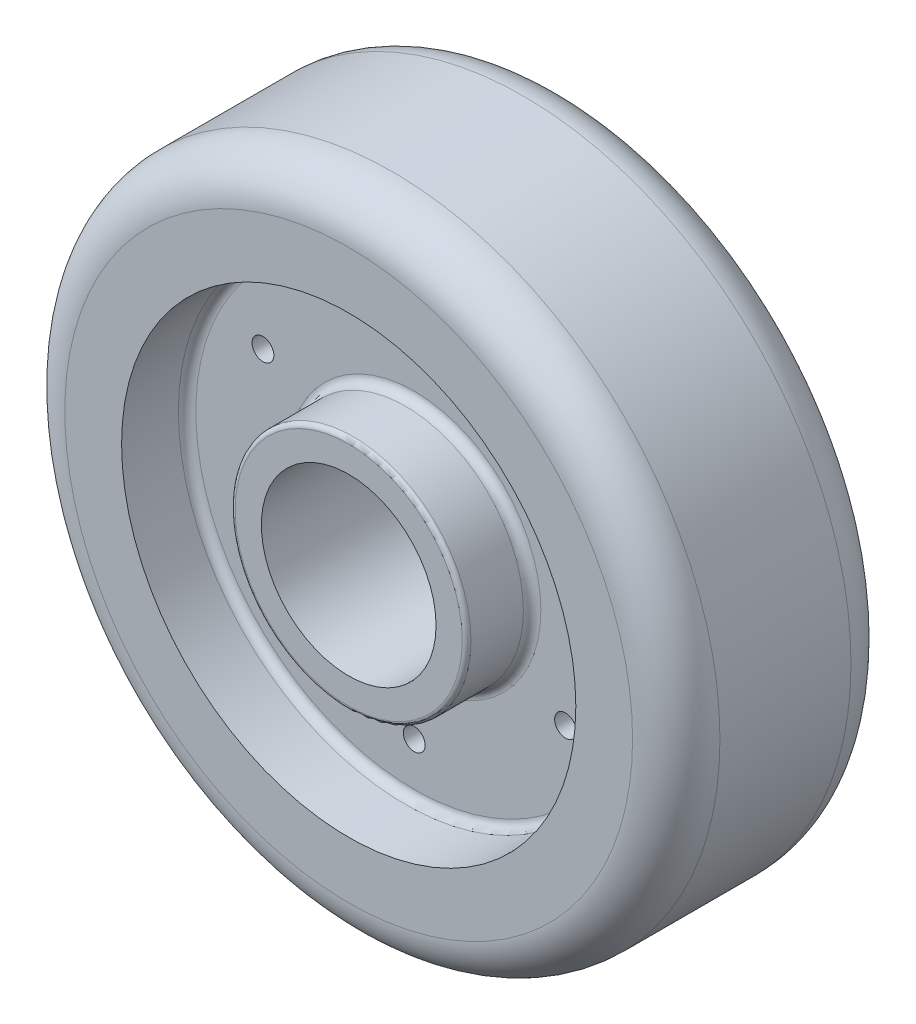
from build123d import *

# Parameters (mm, degrees)
SKETCH1_R           = 75
BOSS_EXTRUDE1_DEPTH = 25
SKETCH2_R           = 52
CUT_EXTRUDE1_DEPTH  = 15
SKETCH3_R           = 52
CUT_EXTRUDE2_DEPTH  = 15
SKETCH4_R           = 27
SKETCH4_R_2         = 20
BOSS_EXTRUDE2_DEPTH = 15
FILLET1_R           = 10
FILLET2_R           = 2
FILLET3_R           = 2
FILLET4_R           = 1
FILLET5_R           = 2
FILLET6_R           = 1
SKETCH7_R           = 20
CUT_EXTRUDE3_DEPTH  = 36.0000001
SKETCH8_R           = 2.5
CUT_EXTRUDE4_DEPTH  = 36.0000001


with BuildPart() as part:
    # Sketch1 → Boss-Extrude1 (new body, symmetric)
    with BuildSketch(Plane.XY):
        Circle(SKETCH1_R)
    extrude(amount=BOSS_EXTRUDE1_DEPTH, both=True)

    # Sketch2 → Cut-Extrude1 (cut)
    with BuildSketch(Plane.XY.offset(25)):
        Circle(SKETCH2_R)
    extrude(amount=-CUT_EXTRUDE1_DEPTH, mode=Mode.SUBTRACT)

    # Sketch3 → Cut-Extrude2 (cut)
    with BuildSketch(Plane(origin=(0, 0, -25), x_dir=(-1, 0, 0), z_dir=(0, 0, -1))):
        Circle(SKETCH3_R)
    extrude(amount=-CUT_EXTRUDE2_DEPTH, mode=Mode.SUBTRACT)

    # Sketch4 → Boss-Extrude2 (add)
    with BuildSketch(Plane.XY.offset(10)):
        Circle(SKETCH4_R)
        Circle(SKETCH4_R_2, mode=Mode.SUBTRACT)
    boss_extrude2 = extrude(amount=BOSS_EXTRUDE2_DEPTH)

    # Fillet1
    fillet1_edges = [part.edges().sort_by_distance(p)[0] for p in [
        (-75, 0, -25),
        (-75, 0, 25),
    ]]
    fillet(fillet1_edges, radius=FILLET1_R)

    # Fillet2
    fillet2_edges = [part.edges().sort_by_distance(p)[0] for p in [
        (-52, 0, 10),
    ]]
    fillet(fillet2_edges, radius=FILLET2_R)

    # Fillet3
    fillet3_edges = [part.edges().sort_by_distance(p)[0] for p in [
        (-27, 0, 10),
    ]]
    fillet(fillet3_edges, radius=FILLET3_R)

    # Fillet4
    fillet4_edges = [part.edges().sort_by_distance(p)[0] for p in [
        (-27, 0, 25),
    ]]
    fillet(fillet4_edges, radius=FILLET4_R)

    # Mirror1: Boss-Extrude2 across plane
    add(boss_extrude2.mirror(Plane.XY))

    # Fillet5
    fillet5_edges = [part.edges().sort_by_distance(p)[0] for p in [
        (52, 0, -10),
        (-27, 0, -10),
    ]]
    fillet(fillet5_edges, radius=FILLET5_R)

    # Fillet6
    fillet6_edges = [part.edges().sort_by_distance(p)[0] for p in [
        (-27, 0, -25),
    ]]
    fillet(fillet6_edges, radius=FILLET6_R)

    # Sketch7 → Cut-Extrude3 (cut, through all)
    with BuildSketch(Plane.XY.offset(10)):
        Circle(SKETCH7_R)
    extrude(amount=-CUT_EXTRUDE3_DEPTH, mode=Mode.SUBTRACT)

    # Sketch8 → Cut-Extrude4 (cut, through all)
    with BuildSketch(Plane.XY.offset(10)):
        with Locations((0, 40)):
            Circle(SKETCH8_R)
        with Locations((34.641016151, 20)):
            Circle(SKETCH8_R)
        with Locations((34.641016151, -20)):
            Circle(SKETCH8_R)
        with Locations((0, -40)):
            Circle(SKETCH8_R)
        with Locations((-34.641016151, -20)):
            Circle(SKETCH8_R)
        with Locations((-34.641016151, 20)):
            Circle(SKETCH8_R)
    extrude(amount=-CUT_EXTRUDE4_DEPTH, mode=Mode.SUBTRACT)


solid = part.part
